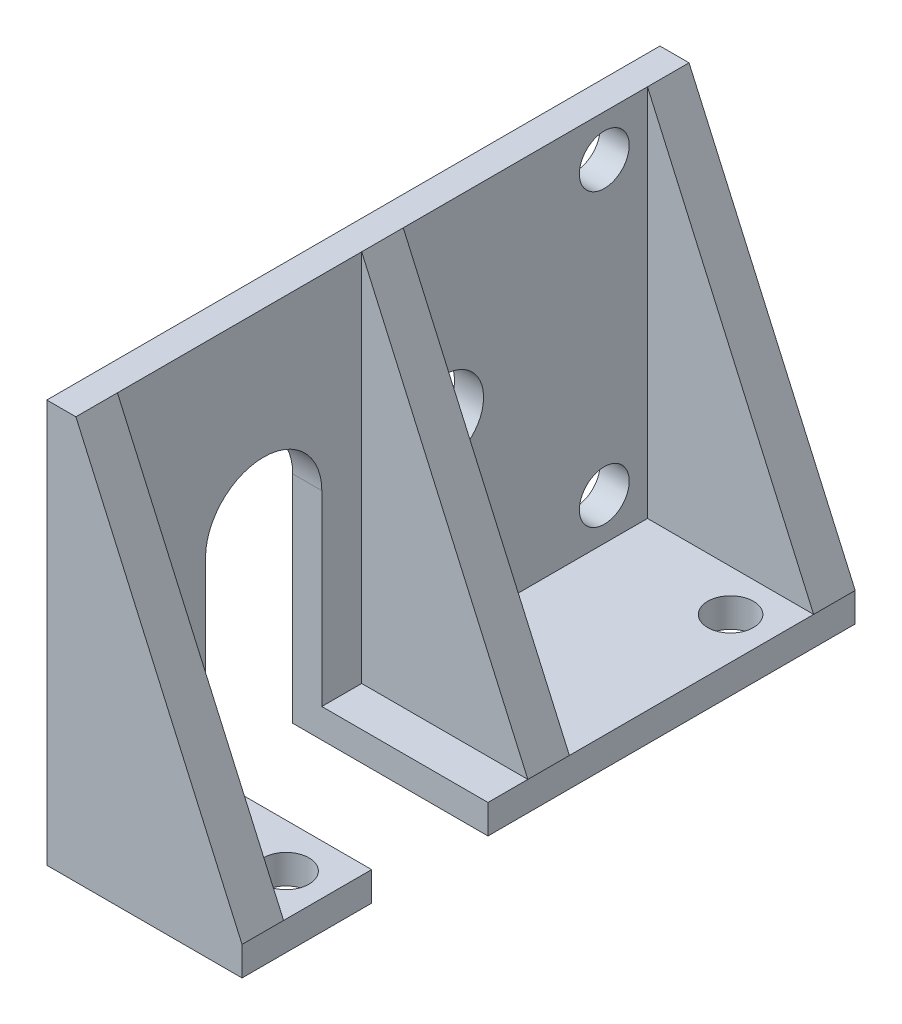
from build123d import *

# Parameters (mm, degrees)
SKETCH1_W                   = 36.9
SKETCH1_H                   = 22.5
BASEPLATE_DEPTH             = 1.75
SKETCH2_W                   = 11.75
SKETCH2_H                   = 36.9
BOSS_EXTRUDE2_DEPTH         = 1.75
SUPPORT1_REACH              = 46.788
SKETCH3_WALL_W              = 116.197196834
SKETCH3_WALL_H              = 2.5
SUPPORT3_REACH              = 33.38
SKETCH4_WALL_W              = 89.382482298
SKETCH4_WALL_H              = 2.5
SKETCH5_R                   = 1.5
MOTOR_MOUNTINGHOLES_DEPTH   = 45.360568076
SHAFTSLOT_DEPTH             = 45.787526165
SKETCH8_R                   = 1.375
CHASSIS_MOUNTINGHOLES_DEPTH = 45.787526165
SKETCH9_R                   = 2.35
INDENTHOLE_DEPTH            = 10


with BuildPart() as part:
    # Sketch1 → basePlate (new body)
    with BuildSketch(Plane(origin=(0, 0, 0), x_dir=(0, 0, -1), z_dir=(1, 0, 0))):
        with Locations((18.45, 11.25)):
            Rectangle(SKETCH1_W, SKETCH1_H)
    extrude(amount=BASEPLATE_DEPTH)

    # Sketch2 → Boss-Extrude2 (add)
    with BuildSketch(Plane.XZ):
        with Locations((5.875, -18.45)):
            Rectangle(SKETCH2_W, SKETCH2_H)
    extrude(amount=BOSS_EXTRUDE2_DEPTH)

    # Sketch3 wall → support1 (add, up to next)
    with BuildSketch(Plane(origin=(6.75, 11.25, 0), x_dir=(0.406138466053, -0.91381154862, 0), z_dir=(0.91381154862, 0.406138466053, 0)), mode=Mode.PRIVATE) as support1_sk1:
        with Locations((0, 1.25)):
            Rectangle(SKETCH3_WALL_W, SKETCH3_WALL_H)
    support1_tool1 = extrude(support1_sk1.sketch, amount=-SUPPORT1_REACH, mode=Mode.PRIVATE) - part.part
    support1 = support1_tool1.solids().sort_by_distance((6.75, 11.25, 0))[0]
    add(support1)

    # support2: support1 across plane
    add(support1.mirror(Plane.XY.offset(-18.45)))

    # Sketch4 wall → support3 (add, up to next)
    with BuildSketch(Plane(origin=(6.75, 11.25, -18.45), x_dir=(0.406138466053, -0.91381154862, 0), z_dir=(0.91381154862, 0.406138466053, 0)), mode=Mode.PRIVATE) as support3_sk1:
        Rectangle(SKETCH4_WALL_W, SKETCH4_WALL_H)
    support3_tool1 = extrude(support3_sk1.sketch, amount=-SUPPORT3_REACH, mode=Mode.PRIVATE) - part.part
    add(support3_tool1.solids().sort_by_distance((6.75, 11.25, -18.45))[0])

    # Sketch5 → motor_mountingHoles (cut, through all)
    with BuildSketch(Plane(origin=(1.75, 0, 0), x_dir=(0, 0, -1), z_dir=(1, 0, 0))):
        with Locations(Location((31.8, 2.5, 0), (0, 0, 180))):
            Circle(SKETCH5_R)
        with Locations(Location((31.8, 20, 0), (0, 0, 180))):
            Circle(SKETCH5_R)
    extrude(amount=-MOTOR_MOUNTINGHOLES_DEPTH, mode=Mode.SUBTRACT)

    # Sketch7 → shaftSlot (cut, through all)
    with BuildSketch(Plane(origin=(11.75, 0, 0), x_dir=(0, 0, -1), z_dir=(1, 0, 0))):
        with BuildLine():
            Line((7.8, -1.75), (7.8, 11.25))
            ThreePointArc((7.8, 11.25), (11.3, 14.75), (14.8, 11.25))
            Line((14.8, 11.25), (14.8, -1.75))
            Line((14.8, -1.75), (7.8, -1.75))
        make_face()
    extrude(amount=-SHAFTSLOT_DEPTH, mode=Mode.SUBTRACT)

    # Sketch8 → chassis_mountingHoles (cut, through all)
    with BuildSketch(Plane(origin=(0, 0, 0), x_dir=(1, 0, 0), z_dir=(0, 1, 0))):
        with Locations(Location((9.25, 5.15, 0), (0, 0, 90))):
            Circle(SKETCH8_R)
        with Locations(Location((9.25, 31.9, 0), (0, 0, 90))):
            Circle(SKETCH8_R)
        with Locations(Location((4.25, 22.2, 0), (0, 0, 90))):
            Circle(SKETCH8_R)
    extrude(amount=-CHASSIS_MOUNTINGHOLES_DEPTH, mode=Mode.SUBTRACT)

    # Sketch9 → indentHole (cut)
    with BuildSketch(Plane(origin=(1.75, 0, 0), x_dir=(0, 0, -1), z_dir=(1, 0, 0))):
        with Locations(Location((22.185, 11.25, 0), (0, 0, 180))):
            Circle(SKETCH9_R)
    extrude(amount=-INDENTHOLE_DEPTH, mode=Mode.SUBTRACT)


solid = part.part
